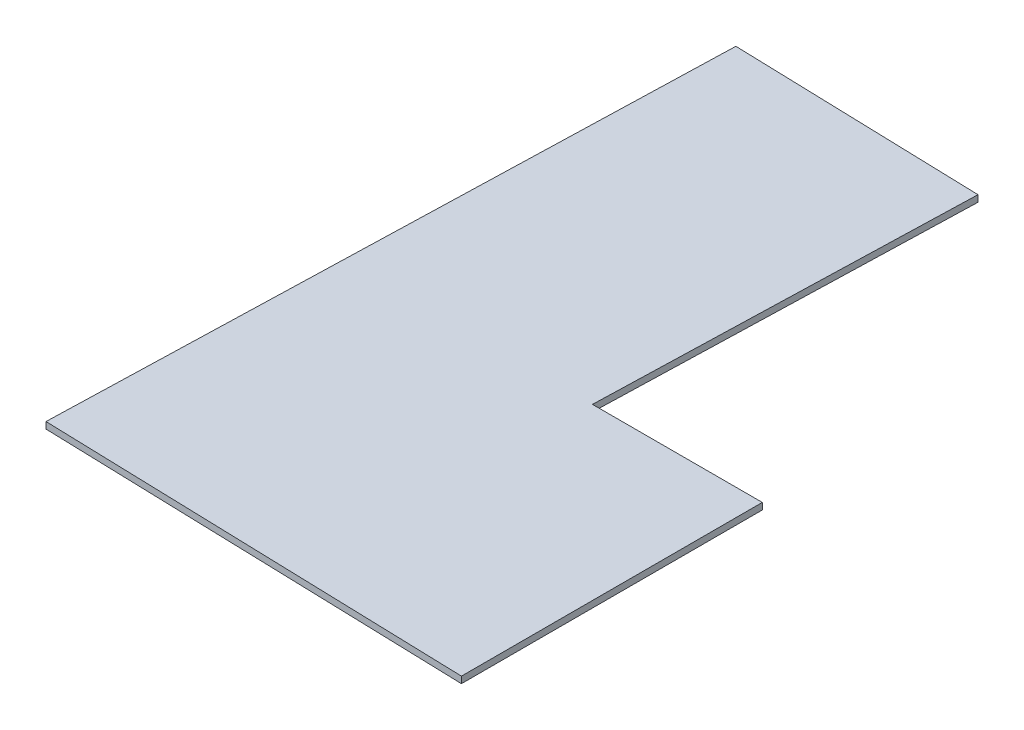
from build123d import *

# Parameters (mm, degrees)
BOSS_EXTRUDE1_DEPTH = 3.175


with BuildPart() as part:
    # Sketch1 → Boss-Extrude1 (new body)
    with BuildSketch(Plane(origin=(0, 0, 0), x_dir=(1, 0, 0), z_dir=(0, 1, 0))):
        Polygon((-241.11287042, -200.926894996), (-159.013594879, -200.926894996), (-159.013594879, -346.377266224), (-366.023594879, -340.203949897), (-356.365952773, -16.353949897), (-235.715952773, -19.951894996), align=None)
    extrude(amount=BOSS_EXTRUDE1_DEPTH)


solid = part.part
